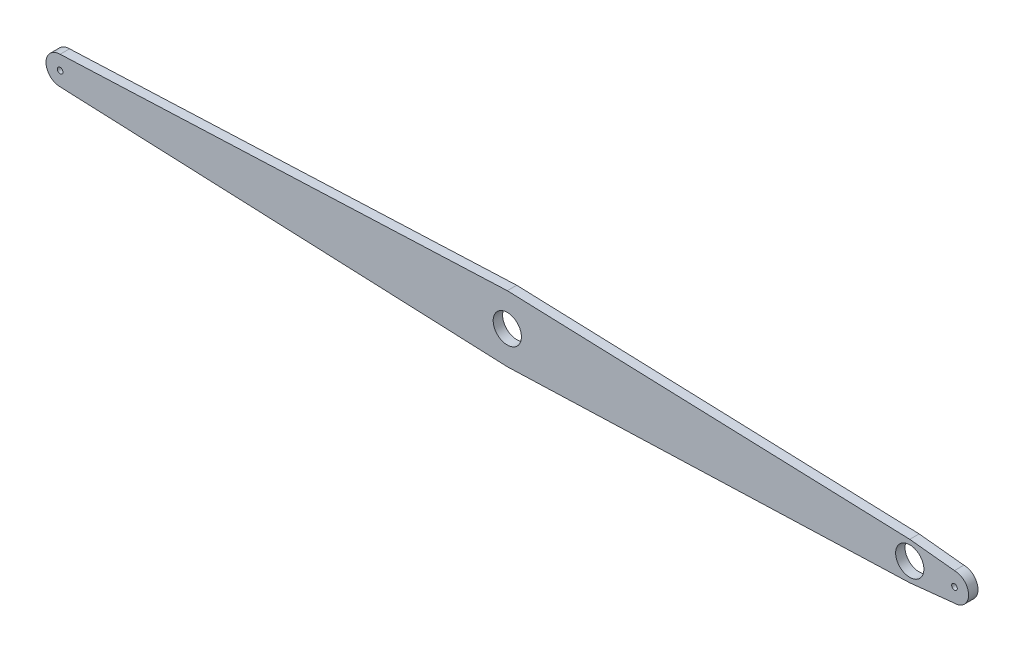
from build123d import *

# Parameters (mm, degrees)
SKIZZE1_R                       = 30
SKIZZE1_R_2                     = 6
AUFSATZ_LINEAR_AUSTRAGEN1_DEPTH = 20


with BuildPart() as part:
    # Skizze1 → Aufsatz-Linear austragen1 (new body)
    with BuildSketch(Plane.XY):
        with BuildLine():
            Line((-950, 70), (-95, 40))
            Line((-95, 40), (0, 30))
            ThreePointArc((0, 30), (30, 0), (0, -30))
            Line((0, -30), (-95, -40))
            Line((-95, -40), (-950, -70))
            Line((-950, -70), (-1900, -30))
            ThreePointArc((-1900, -30), (-1930, 0), (-1900, 30))
            Line((-1900, 30), (-950, 70))
        make_face()
        with Locations((-950, 0)):
            Circle(SKIZZE1_R, mode=Mode.SUBTRACT)
        with Locations((-95, 0)):
            Circle(SKIZZE1_R, mode=Mode.SUBTRACT)
        with Locations((-1900, 0)):
            Circle(SKIZZE1_R_2, mode=Mode.SUBTRACT)
        Circle(SKIZZE1_R_2, mode=Mode.SUBTRACT)
    extrude(amount=AUFSATZ_LINEAR_AUSTRAGEN1_DEPTH)


solid = part.part
